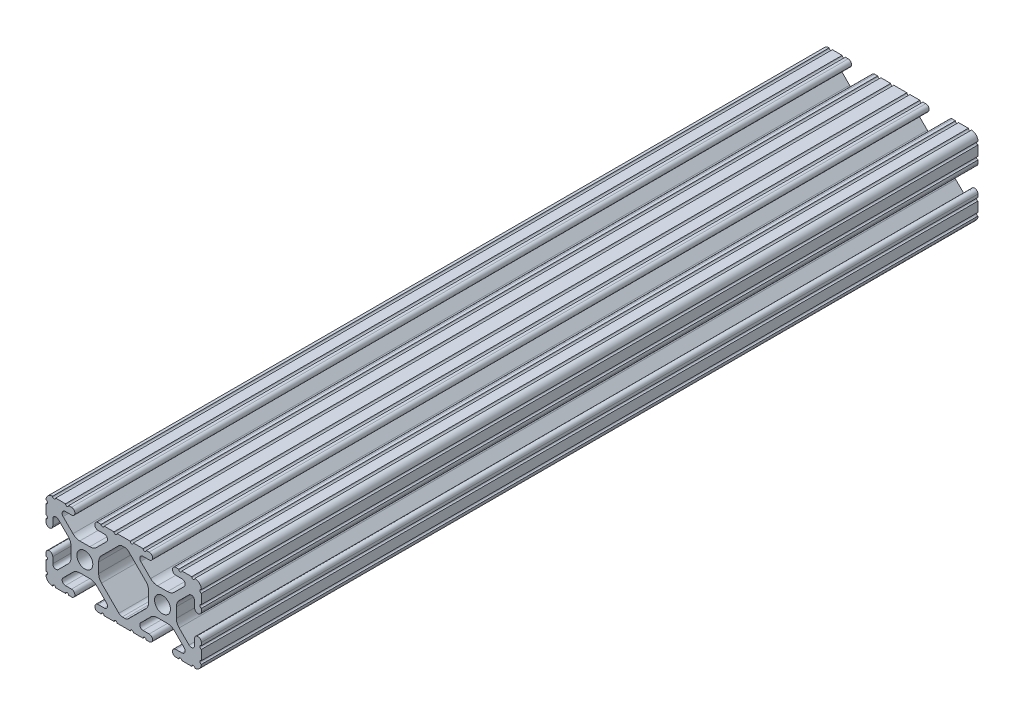
from build123d import *

# Parameters (mm, degrees)
SKETCH1_R      = 2.6035
EXTRUDE1_DEPTH = 254


with BuildPart() as part:
    # Sketch1 → Extrude1 (new body)
    with BuildSketch(Plane.XY):
        with BuildLine():
            Line((25.4, -10.5918), (25.4, -10.5664))
            ThreePointArc((25.4, -10.5664), (24.892, -10.0584), (25.4, -9.5504))
            Line((25.4, -9.5504), (25.4, -6.3246))
            ThreePointArc((25.4, -6.3246), (24.892, -5.8166), (25.4, -5.3086))
            Line((25.4, -5.3086), (25.4, -4.3561))
            ThreePointArc((25.4, -4.3561), (24.2951, -3.2512), (23.1902, -4.3561))
            Line((23.1902, -4.3561), (23.1902, -6.370083786))
            ThreePointArc((23.1902, -6.370083786), (22.536204819, -7.348856743), (21.381663397, -7.119204175))
            Line((21.381663397, -7.119204175), (18.147103113, -3.88464389))
            ThreePointArc((18.147103113, -3.88464389), (17.458849627, -2.854599758), (17.217167143, -1.63957986))
            Line((17.217167143, -1.63957986), (17.217167143, 1.63957986))
            ThreePointArc((17.217167143, 1.63957986), (17.458849627, 2.854599758), (18.147103113, 3.88464389))
            Line((18.147103113, 3.88464389), (21.381663397, 7.119204175))
            ThreePointArc((21.381663397, 7.119204175), (22.536204819, 7.348856743), (23.1902, 6.370083786))
            Line((23.1902, 6.370083786), (23.1902, 4.3561))
            ThreePointArc((23.1902, 4.3561), (24.2951, 3.2512), (25.4, 4.3561))
            Line((25.4, 4.3561), (25.4, 5.3086))
            ThreePointArc((25.4, 5.3086), (24.892, 5.8166), (25.4, 6.3246))
            Line((25.4, 6.3246), (25.4, 9.5504))
            ThreePointArc((25.4, 9.5504), (24.892, 10.0584), (25.4, 10.5664))
            Line((25.4, 10.5664), (25.4, 10.5918))
            ThreePointArc((25.4, 10.5918), (24.782522516, 12.082522516), (23.2918, 12.7))
            Line((23.2918, 12.7), (23.2664, 12.7))
            ThreePointArc((23.2664, 12.7), (22.7584, 12.192), (22.2504, 12.7))
            Line((22.2504, 12.7), (19.0246, 12.7))
            ThreePointArc((19.0246, 12.7), (18.5166, 12.192), (18.0086, 12.7))
            Line((18.0086, 12.7), (17.0561, 12.7))
            ThreePointArc((17.0561, 12.7), (15.9512, 11.5951), (17.0561, 10.4902))
            Line((17.0561, 10.4902), (19.070083786, 10.4902))
            ThreePointArc((19.070083786, 10.4902), (20.048856743, 9.836204819), (19.819204175, 8.681663397))
            Line((19.819204175, 8.681663397), (16.58464389, 5.447103113))
            ThreePointArc((16.58464389, 5.447103113), (15.554599758, 4.758849627), (14.33957986, 4.517167143))
            Line((14.33957986, 4.517167143), (11.06042014, 4.517167143))
            ThreePointArc((11.06042014, 4.517167143), (9.845400242, 4.758849627), (8.81535611, 5.447103113))
            Line((8.81535611, 5.447103113), (5.580795825, 8.681663397))
            ThreePointArc((5.580795825, 8.681663397), (5.351143257, 9.836204819), (6.329916214, 10.4902))
            Line((6.329916214, 10.4902), (8.3439, 10.4902))
            ThreePointArc((8.3439, 10.4902), (9.4488, 11.5951), (8.3439, 12.7))
            Line((8.3439, 12.7), (7.3914, 12.7))
            ThreePointArc((7.3914, 12.7), (6.8834, 12.192), (6.3754, 12.7))
            Line((6.3754, 12.7), (3.1496, 12.7))
            ThreePointArc((3.1496, 12.7), (2.6416, 12.192), (2.1336, 12.7))
            Line((2.1336, 12.7), (-2.1336, 12.7))
            ThreePointArc((-2.1336, 12.7), (-2.6416, 12.192), (-3.1496, 12.7))
            Line((-3.1496, 12.7), (-6.3754, 12.7))
            ThreePointArc((-6.3754, 12.7), (-6.8834, 12.192), (-7.3914, 12.7))
            Line((-7.3914, 12.7), (-8.3439, 12.7))
            ThreePointArc((-8.3439, 12.7), (-9.4488, 11.5951), (-8.3439, 10.4902))
            Line((-8.3439, 10.4902), (-6.329916214, 10.4902))
            ThreePointArc((-6.329916214, 10.4902), (-5.351143257, 9.836204819), (-5.580795825, 8.681663397))
            Line((-5.580795825, 8.681663397), (-8.81535611, 5.447103113))
            ThreePointArc((-8.81535611, 5.447103113), (-9.845400242, 4.758849627), (-11.06042014, 4.517167143))
            Line((-11.06042014, 4.517167143), (-14.33957986, 4.517167143))
            ThreePointArc((-14.33957986, 4.517167143), (-15.554599758, 4.758849627), (-16.58464389, 5.447103113))
            Line((-16.58464389, 5.447103113), (-19.819204175, 8.681663397))
            ThreePointArc((-19.819204175, 8.681663397), (-20.048856743, 9.836204819), (-19.070083786, 10.4902))
            Line((-19.070083786, 10.4902), (-17.0561, 10.4902))
            ThreePointArc((-17.0561, 10.4902), (-15.9512, 11.5951), (-17.0561, 12.7))
            Line((-17.0561, 12.7), (-18.0086, 12.7))
            ThreePointArc((-18.0086, 12.7), (-18.5166, 12.192), (-19.0246, 12.7))
            Line((-19.0246, 12.7), (-22.2504, 12.7))
            ThreePointArc((-22.2504, 12.7), (-22.7584, 12.192), (-23.2664, 12.7))
            Line((-23.2664, 12.7), (-23.2918, 12.7))
            ThreePointArc((-23.2918, 12.7), (-24.782522516, 12.082522516), (-25.4, 10.5918))
            Line((-25.4, 10.5918), (-25.4, 10.5664))
            ThreePointArc((-25.4, 10.5664), (-24.892, 10.0584), (-25.4, 9.5504))
            Line((-25.4, 9.5504), (-25.4, 6.3246))
            ThreePointArc((-25.4, 6.3246), (-24.892, 5.8166), (-25.4, 5.3086))
            Line((-25.4, 5.3086), (-25.4, 4.3561))
            ThreePointArc((-25.4, 4.3561), (-24.2951, 3.2512), (-23.1902, 4.3561))
            Line((-23.1902, 4.3561), (-23.1902, 6.370083786))
            ThreePointArc((-23.1902, 6.370083786), (-22.536204819, 7.348856743), (-21.381663397, 7.119204175))
            Line((-21.381663397, 7.119204175), (-18.147103113, 3.88464389))
            ThreePointArc((-18.147103113, 3.88464389), (-17.458849627, 2.854599758), (-17.217167143, 1.63957986))
            Line((-17.217167143, 1.63957986), (-17.217167143, -1.63957986))
            ThreePointArc((-17.217167143, -1.63957986), (-17.458849627, -2.854599758), (-18.147103113, -3.88464389))
            Line((-18.147103113, -3.88464389), (-21.381663397, -7.119204175))
            ThreePointArc((-21.381663397, -7.119204175), (-22.536204819, -7.348856743), (-23.1902, -6.370083786))
            Line((-23.1902, -6.370083786), (-23.1902, -4.3561))
            ThreePointArc((-23.1902, -4.3561), (-24.2951, -3.2512), (-25.4, -4.3561))
            Line((-25.4, -4.3561), (-25.4, -5.3086))
            ThreePointArc((-25.4, -5.3086), (-24.892, -5.8166), (-25.4, -6.3246))
            Line((-25.4, -6.3246), (-25.4, -9.5504))
            ThreePointArc((-25.4, -9.5504), (-24.892, -10.0584), (-25.4, -10.5664))
            Line((-25.4, -10.5664), (-25.4, -10.5918))
            ThreePointArc((-25.4, -10.5918), (-24.782522516, -12.082522516), (-23.2918, -12.7))
            Line((-23.2918, -12.7), (-23.2664, -12.7))
            ThreePointArc((-23.2664, -12.7), (-22.7584, -12.192), (-22.2504, -12.7))
            Line((-22.2504, -12.7), (-19.0246, -12.7))
            ThreePointArc((-19.0246, -12.7), (-18.5166, -12.192), (-18.0086, -12.7))
            Line((-18.0086, -12.7), (-17.0561, -12.7))
            ThreePointArc((-17.0561, -12.7), (-15.9512, -11.5951), (-17.0561, -10.4902))
            Line((-17.0561, -10.4902), (-19.070083786, -10.4902))
            ThreePointArc((-19.070083786, -10.4902), (-20.048856743, -9.836204819), (-19.819204175, -8.681663397))
            Line((-19.819204175, -8.681663397), (-16.58464389, -5.447103113))
            ThreePointArc((-16.58464389, -5.447103113), (-15.554599758, -4.758849627), (-14.33957986, -4.517167143))
            Line((-14.33957986, -4.517167143), (-11.06042014, -4.517167143))
            ThreePointArc((-11.06042014, -4.517167143), (-9.845400242, -4.758849627), (-8.81535611, -5.447103113))
            Line((-8.81535611, -5.447103113), (-5.580795825, -8.681663397))
            ThreePointArc((-5.580795825, -8.681663397), (-5.351143257, -9.836204819), (-6.329916214, -10.4902))
            Line((-6.329916214, -10.4902), (-8.3439, -10.4902))
            ThreePointArc((-8.3439, -10.4902), (-9.4488, -11.5951), (-8.3439, -12.7))
            Line((-8.3439, -12.7), (-7.3914, -12.7))
            ThreePointArc((-7.3914, -12.7), (-6.8834, -12.192), (-6.3754, -12.7))
            Line((-6.3754, -12.7), (-3.1496, -12.7))
            ThreePointArc((-3.1496, -12.7), (-2.6416, -12.192), (-2.1336, -12.7))
            Line((-2.1336, -12.7), (2.1336, -12.7))
            ThreePointArc((2.1336, -12.7), (2.6416, -12.192), (3.1496, -12.7))
            Line((3.1496, -12.7), (6.3754, -12.7))
            ThreePointArc((6.3754, -12.7), (6.8834, -12.192), (7.3914, -12.7))
            Line((7.3914, -12.7), (8.3439, -12.7))
            ThreePointArc((8.3439, -12.7), (9.4488, -11.5951), (8.3439, -10.4902))
            Line((8.3439, -10.4902), (6.329916214, -10.4902))
            ThreePointArc((6.329916214, -10.4902), (5.351143257, -9.836204819), (5.580795825, -8.681663397))
            Line((5.580795825, -8.681663397), (8.81535611, -5.447103113))
            ThreePointArc((8.81535611, -5.447103113), (9.845400242, -4.758849627), (11.06042014, -4.517167143))
            Line((11.06042014, -4.517167143), (14.33957986, -4.517167143))
            ThreePointArc((14.33957986, -4.517167143), (15.554599758, -4.758849627), (16.58464389, -5.447103113))
            Line((16.58464389, -5.447103113), (19.819204175, -8.681663397))
            ThreePointArc((19.819204175, -8.681663397), (20.048856743, -9.836204819), (19.070083786, -10.4902))
            Line((19.070083786, -10.4902), (17.0561, -10.4902))
            ThreePointArc((17.0561, -10.4902), (15.9512, -11.5951), (17.0561, -12.7))
            Line((17.0561, -12.7), (18.0086, -12.7))
            ThreePointArc((18.0086, -12.7), (18.5166, -12.192), (19.0246, -12.7))
            Line((19.0246, -12.7), (22.2504, -12.7))
            ThreePointArc((22.2504, -12.7), (22.7584, -12.192), (23.2664, -12.7))
            Line((23.2664, -12.7), (23.2918, -12.7))
            ThreePointArc((23.2918, -12.7), (24.782522516, -12.082522516), (25.4, -10.5918))
        make_face()
        with Locations((-12.7, 0)):
            Circle(SKETCH1_R, mode=Mode.SUBTRACT)
        with Locations((12.7, 0)):
            Circle(SKETCH1_R, mode=Mode.SUBTRACT)
        with BuildLine():
            Line((-8.182832857, -1.639369175), (-8.182832857, 1.639369175))
            ThreePointArc((-8.182832857, 1.639369175), (-7.941150373, 2.854389072), (-7.252896887, 3.884433205))
            Line((-7.252896887, 3.884433205), (-1.565578333, 9.571751759))
            ThreePointArc((-1.565578333, 9.571751759), (-1.054676443, 9.913125488), (-0.452026574, 10.033))
            Line((-0.452026574, 10.033), (0.452026574, 10.033))
            ThreePointArc((0.452026574, 10.033), (1.054676443, 9.913125488), (1.565578333, 9.571751759))
            Line((1.565578333, 9.571751759), (7.252896887, 3.884433205))
            ThreePointArc((7.252896887, 3.884433205), (7.941150373, 2.854389072), (8.182832857, 1.639369175))
            Line((8.182832857, 1.639369175), (8.182832857, -1.639369175))
            ThreePointArc((8.182832857, -1.639369175), (7.941150373, -2.854389072), (7.252896887, -3.884433205))
            Line((7.252896887, -3.884433205), (1.565578333, -9.571751759))
            ThreePointArc((1.565578333, -9.571751759), (1.054676443, -9.913125488), (0.452026574, -10.033))
            Line((0.452026574, -10.033), (-0.452026574, -10.033))
            ThreePointArc((-0.452026574, -10.033), (-1.054676443, -9.913125488), (-1.565578333, -9.571751759))
            Line((-1.565578333, -9.571751759), (-7.252896887, -3.884433205))
            ThreePointArc((-7.252896887, -3.884433205), (-7.941150373, -2.854389072), (-8.182832857, -1.639369175))
        make_face(mode=Mode.SUBTRACT)
    extrude(amount=-EXTRUDE1_DEPTH)


solid = part.part
